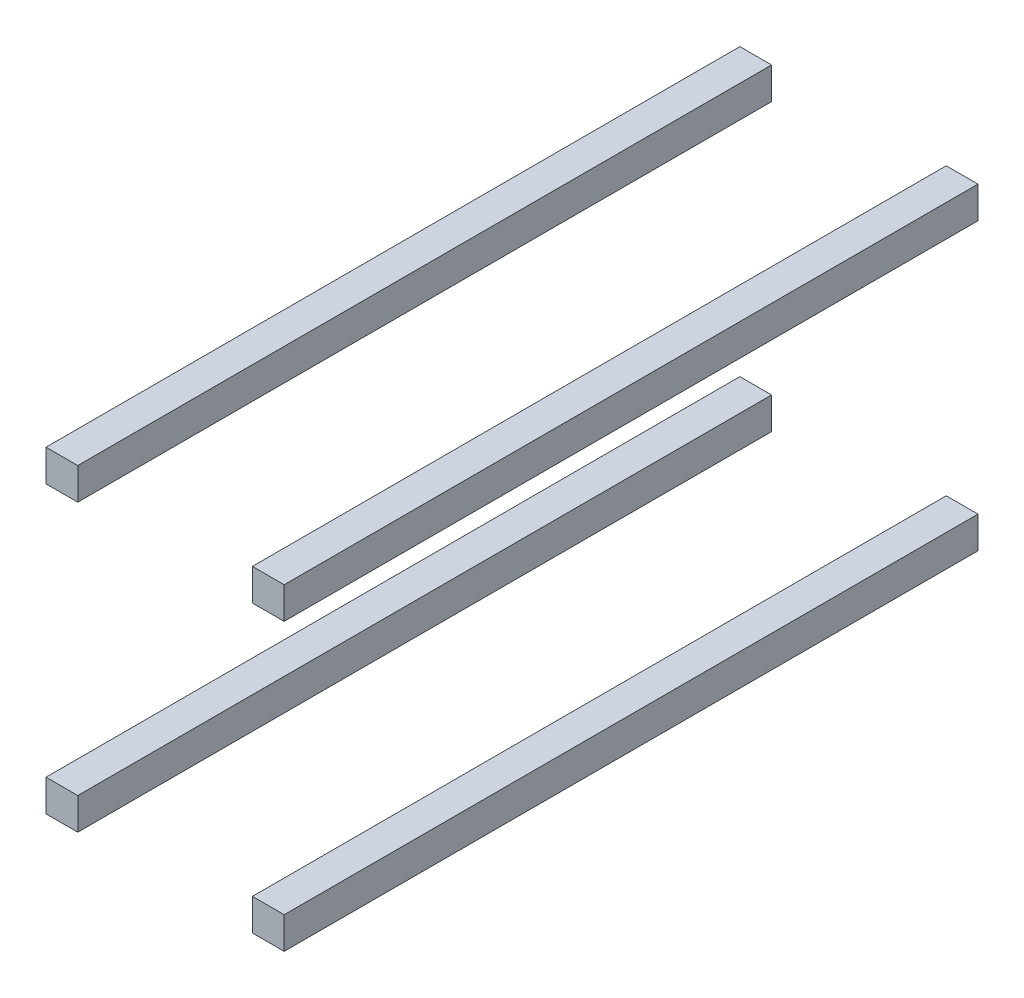
from build123d import *

# Parameters (mm, degrees)
SKETCH1_W             = 20
SKETCH1_H             = 20
BOSS_EXTRUDE1_DEPTH   = 437
BOSS_EXTRUDE1_2_DEPTH = 437
BOSS_EXTRUDE1_3_DEPTH = 437
BOSS_EXTRUDE1_4_DEPTH = 437


with BuildPart() as part:
    # Sketch1 → Boss-Extrude1 (new body)
    with BuildSketch(Plane.XY):
        with Locations((10, 10)):
            Rectangle(SKETCH1_W, SKETCH1_H)
    extrude(amount=BOSS_EXTRUDE1_DEPTH)


with BuildPart() as body_2:
    # Sketch1 → Boss-Extrude1 2 (new body)
    with BuildSketch(Plane.XY):
        with Locations((140, 10)):
            Rectangle(SKETCH1_W, SKETCH1_H)
    extrude(amount=BOSS_EXTRUDE1_2_DEPTH)


with BuildPart() as body_3:
    # Sketch1 → Boss-Extrude1 3 (new body)
    with BuildSketch(Plane.XY):
        with Locations((140, -170)):
            Rectangle(SKETCH1_W, SKETCH1_H)
    extrude(amount=BOSS_EXTRUDE1_3_DEPTH)


with BuildPart() as body_4:
    # Sketch1 → Boss-Extrude1 4 (new body)
    with BuildSketch(Plane.XY):
        with Locations((10, -170)):
            Rectangle(SKETCH1_W, SKETCH1_H)
    extrude(amount=BOSS_EXTRUDE1_4_DEPTH)


solid = Compound([part.part, body_2.part, body_3.part, body_4.part])
